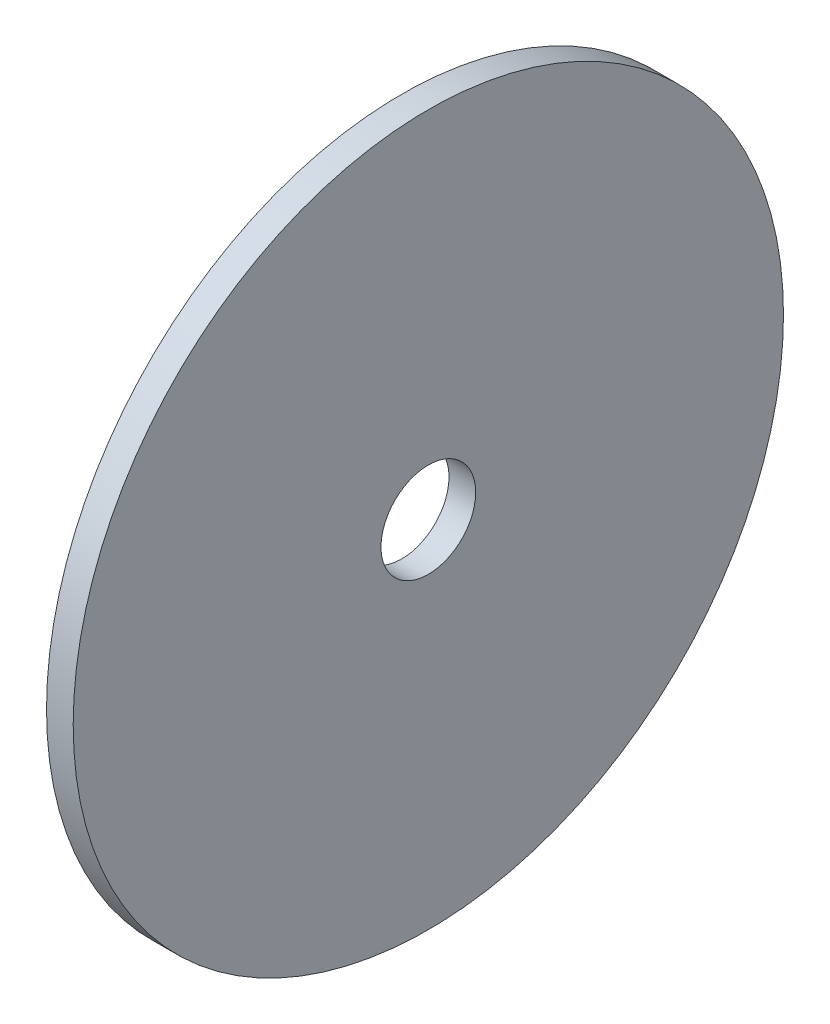
from build123d import *

# Parameters (mm, degrees)
BOSS_EXTRU_2_START = 96
ESQUISSE8_R        = 53.25
ESQUISSE8_R_2      = 7.1
BOSS_EXTRU_2_DEPTH = 4


with BuildPart() as part:
    # Esquisse8 → Boss.-Extru.2 (new body)
    with BuildSketch(Plane(origin=(0, 0, 0), x_dir=(0, 0, -1), z_dir=(1, 0, 0)).offset(BOSS_EXTRU_2_START)):
        Circle(ESQUISSE8_R)
        Circle(ESQUISSE8_R_2, mode=Mode.SUBTRACT)
    extrude(amount=BOSS_EXTRU_2_DEPTH)


solid = part.part
